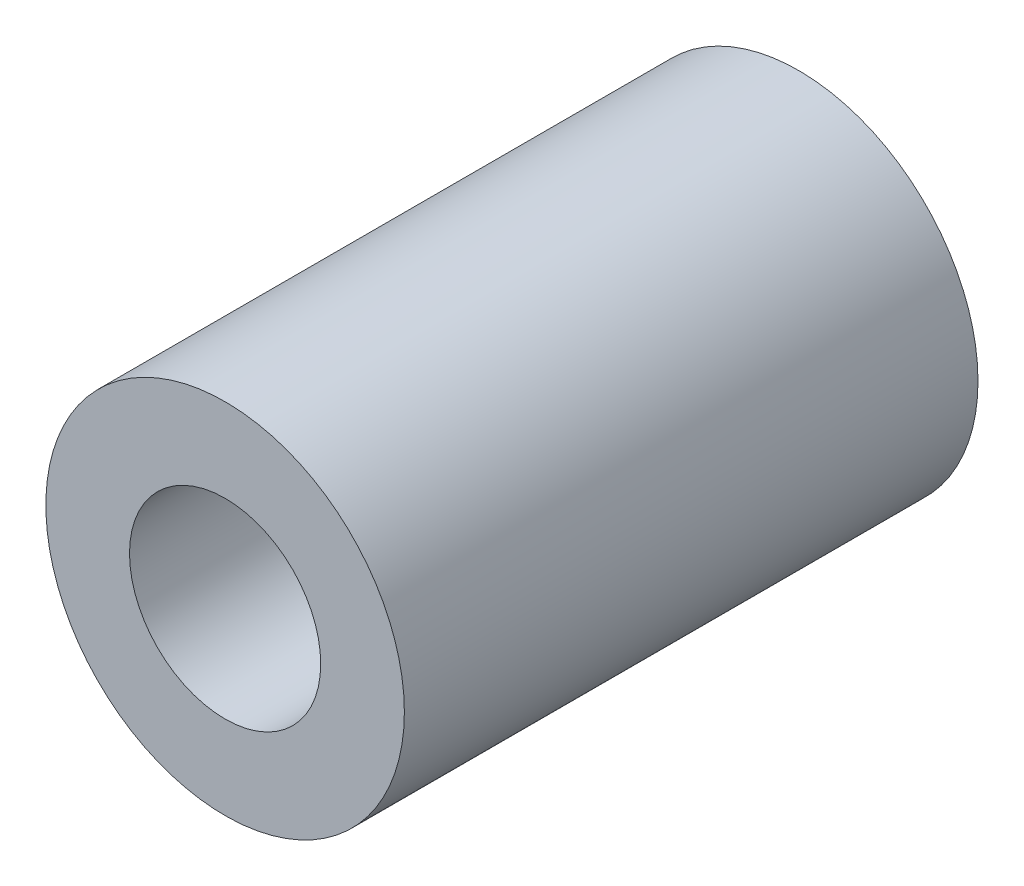
from build123d import *

# Parameters (mm, degrees)
SKETCH1_R           = 7.5
SKETCH1_R_2         = 4
BOSS_EXTRUDE1_DEPTH = 24


with BuildPart() as part:
    # Sketch1 → Boss-Extrude1 (new body)
    with BuildSketch(Plane.XY):
        Circle(SKETCH1_R)
        Circle(SKETCH1_R_2, mode=Mode.SUBTRACT)
    extrude(amount=BOSS_EXTRUDE1_DEPTH)


solid = part.part
